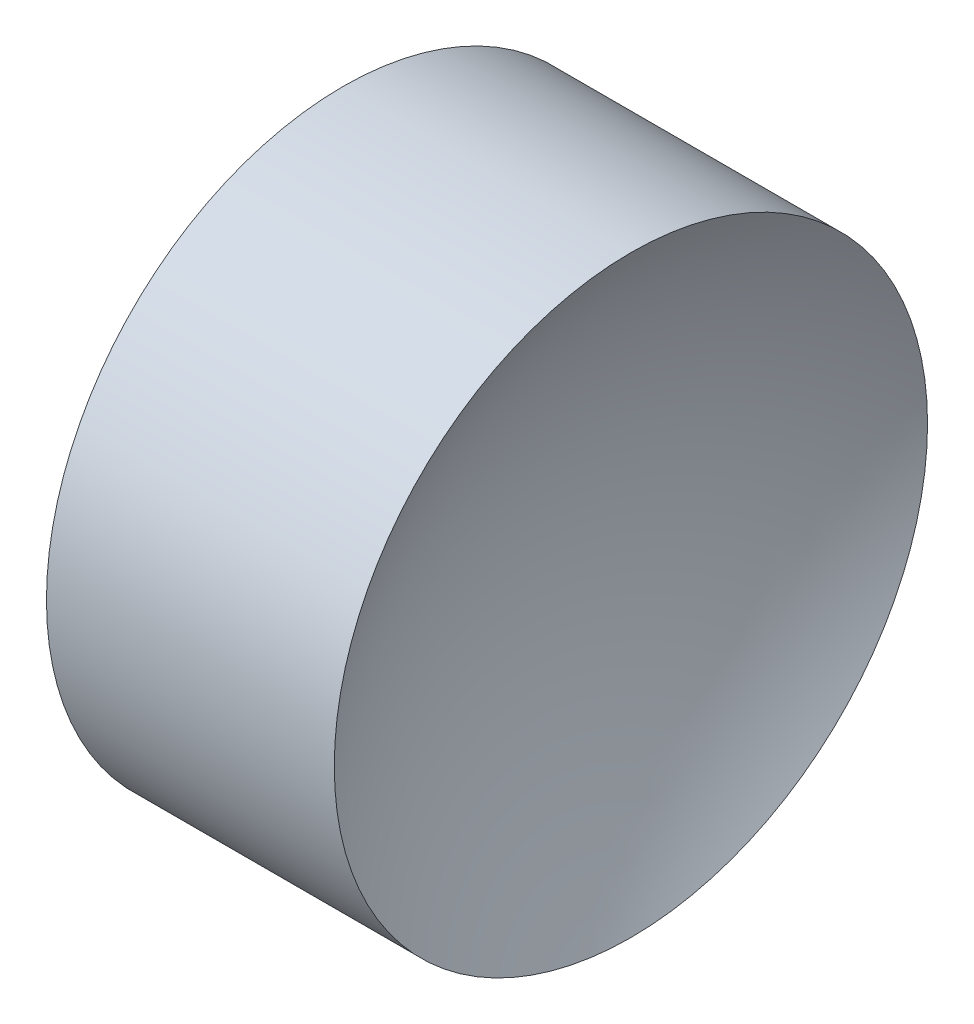
from build123d import *


with BuildPart() as part:
    # 草图1 → 旋转1 (revolve)
    with BuildSketch(Plane.XY):
        with BuildLine():
            Line((23.024256364, 13.044520575), (25.024256364, 13.044520575))
            ThreePointArc((25.024256364, 13.044520575), (25.387667901, 15.644177244), (26.450040077, 18.044520575))
            Line((26.450040077, 18.044520575), (24.024256364, 18.044520575))
            Line((24.024256364, 18.044520575), (21.598472651, 18.044520575))
            ThreePointArc((21.598472651, 18.044520575), (22.660844827, 15.644177244), (23.024256364, 13.044520575))
        make_face()
    revolve(axis=Axis((21.224930557, 13.044520575, 0), (1, 0, 0)))


solid = part.part
